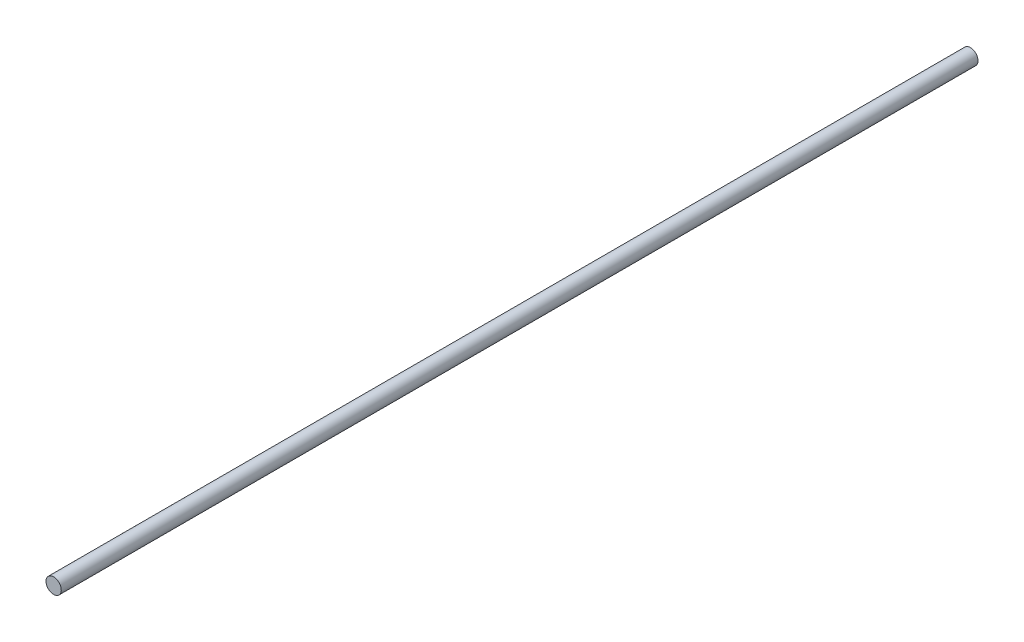
from build123d import *

# Parameters (mm, degrees)
SKETCH1_R           = 9.525
BOSS_EXTRUDE1_DEPTH = 1143


with BuildPart() as part:
    # Sketch1 → Boss-Extrude1 (new body)
    with BuildSketch(Plane.XY):
        Circle(SKETCH1_R)
    extrude(amount=BOSS_EXTRUDE1_DEPTH)


solid = part.part
